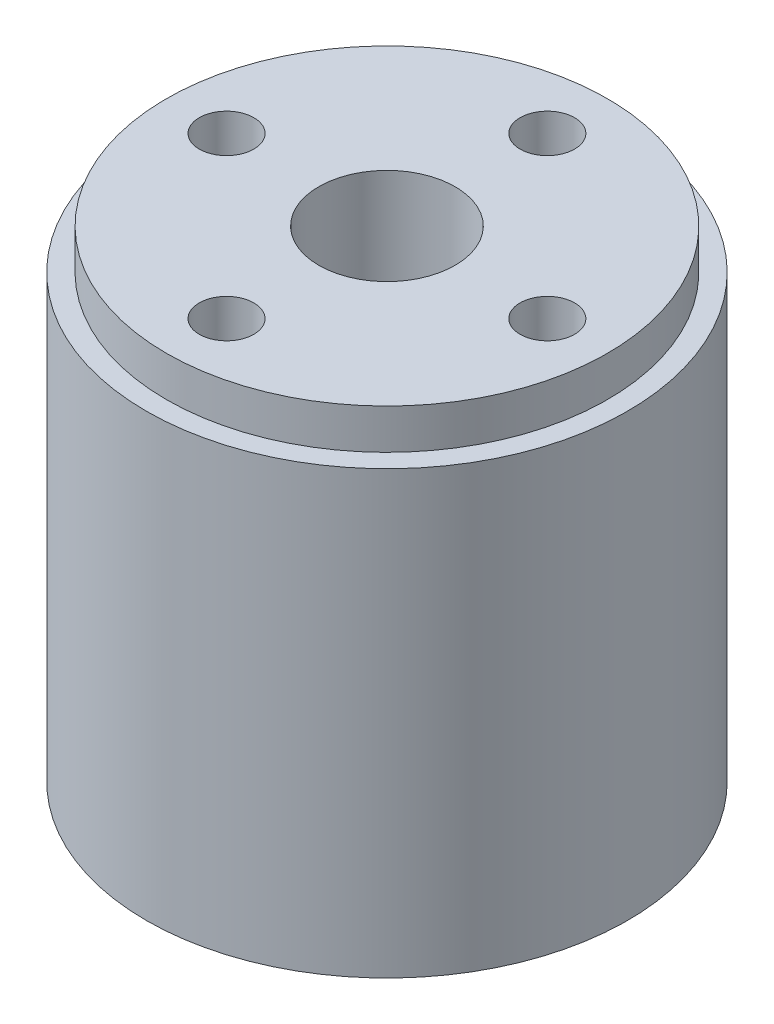
from build123d import *

# Parameters (mm, degrees)
SKETCH1_R           = 30
SKETCH1_R_2         = 8.5
SKETCH1_R_3         = 3.4
BOSS_EXTRUDE1_DEPTH = 60
SKETCH3_R           = 30
SKETCH3_R_2         = 27.5
CUT_EXTRUDE1_DEPTH  = 5
CHAMFER1_SIZE       = 5


with BuildPart() as part:
    # Sketch1 → Boss-Extrude1 (new body)
    with BuildSketch(Plane(origin=(0, 0, 0), x_dir=(1, 0, 0), z_dir=(0, 1, 0))):
        Circle(SKETCH1_R)
        Circle(SKETCH1_R_2, mode=Mode.SUBTRACT)
        with Locations((-20, 0)):
            Circle(SKETCH1_R_3, mode=Mode.SUBTRACT)
        with Locations((0, 20)):
            Circle(SKETCH1_R_3, mode=Mode.SUBTRACT)
        with Locations((20, 0)):
            Circle(SKETCH1_R_3, mode=Mode.SUBTRACT)
        with Locations((0, -20)):
            Circle(SKETCH1_R_3, mode=Mode.SUBTRACT)
    extrude(amount=BOSS_EXTRUDE1_DEPTH)

    # Sketch3 → Cut-Extrude1 (cut)
    with BuildSketch(Plane(origin=(0, 60, 0), x_dir=(1, 0, 0), z_dir=(0, 1, 0))):
        Circle(SKETCH3_R)
        Circle(SKETCH3_R_2, mode=Mode.SUBTRACT)
    extrude(amount=-CUT_EXTRUDE1_DEPTH, mode=Mode.SUBTRACT)

    # Chamfer1
    chamfer1_edges = [part.edges().sort_by_distance(p)[0] for p in [
        (-8.5, 0, 0),
    ]]
    chamfer(chamfer1_edges, length=CHAMFER1_SIZE)


solid = part.part
